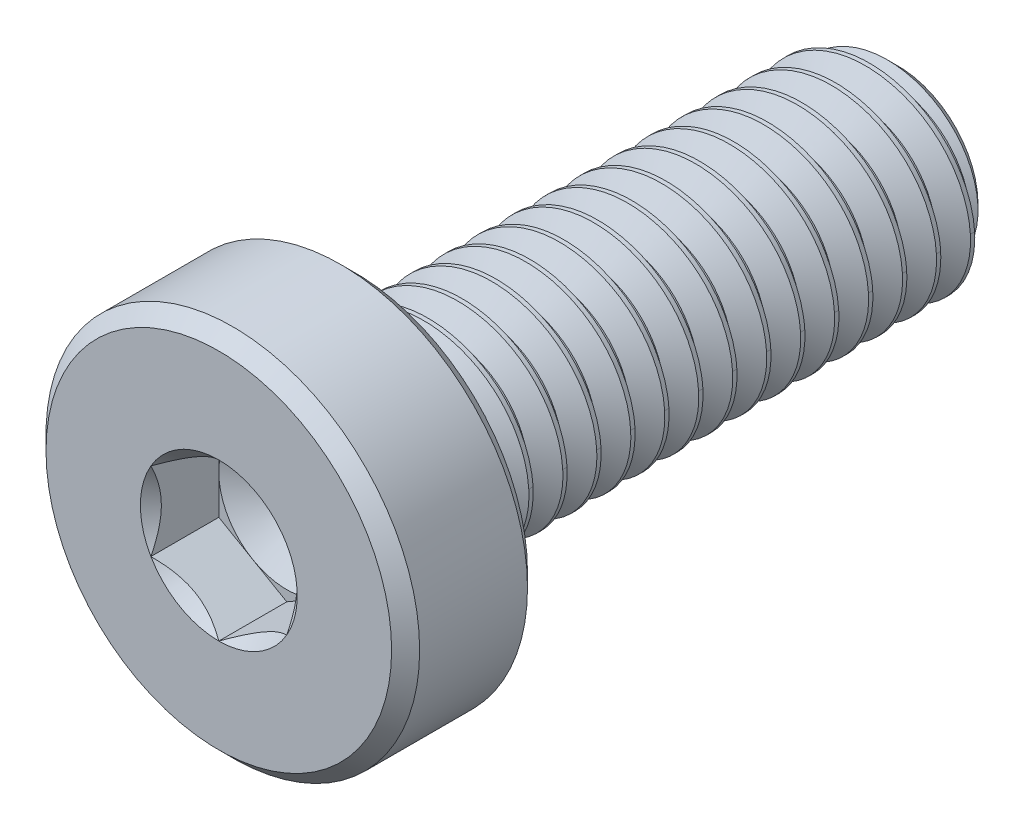
from build123d import *

# Parameters (mm, degrees)
CUT_EXTRUDE1_DEPTH     = 1
CUT_SWEEP1_PITCH       = 0.5
CUT_SWEEP1_HEIGHT      = 8.3125
CUT_SWEEP1_RADIUS      = 1.5
CUT_SWEEP1_START_ANGLE = 90


with BuildPart() as part:
    # Sketch2 → Revolve1 (revolve)
    with BuildSketch(Plane(origin=(0, 0, 0), x_dir=(0, 0, -1), z_dir=(1, 0, 0)), mode=Mode.PRIVATE) as revolve1_sk:
        with BuildLine():
            Line((-3.20625, 2.75), (-3, 2.54375))
            Line((-3, 2.54375), (-3, 1.65))
            ThreePointArc((-3, 1.65), (-2.956066017, 1.543933983), (-2.85, 1.5))
            Line((-2.85, 1.5), (4.675240474, 1.5))
            Line((4.675240474, 1.5), (5, 1.175240474))
            Line((5, 1.175240474), (5, 0))
            Line((5, 0), (-4, 0))
            Line((-4, 0), (-4, 1))
            Line((-4, 1), (-5, 1))
            Line((-5, 1), (-5, 2.54375))
            Line((-5, 2.54375), (-4.79375, 2.75))
            Line((-4.79375, 2.75), (-3.20625, 2.75))
        make_face()
    revolve(revolve1_sk.sketch.rotate(Axis((0, 0, 4), (0, 0, -1)), 90), axis=Axis((0, 0, 4), (0, 0, -1)))

    # Sketch3 → Cut-Extrude1 (cut)
    with BuildSketch(Plane.XY.offset(5)):
        Polygon((0, 1.154700538), (-1, 0.577350269), (-1, -0.577350269), (0, -1.154700538), (1, -0.577350269), (1, 0.577350269), align=None)
    extrude(amount=-CUT_EXTRUDE1_DEPTH, mode=Mode.SUBTRACT)

    # Cut-Extrude2 cone 1 section (through the dimple's axis) → Cut-Extrude2 (revolve, cut)
    with BuildSketch(Plane(origin=(0, 0, 5), x_dir=(0, -1, 0), z_dir=(1, 0, 0))):
        Polygon((0, 0), (1.154700538, 0), (0, 1.154700538), align=None)
    revolve(axis=Axis((0, 0, 5), (0, 0, -1)), mode=Mode.SUBTRACT)

    # Cut-Extrude5 cone 1 section (through the dimple's axis) → Cut-Extrude5 (revolve, cut)
    with BuildSketch(Plane(origin=(0, 0, 4), x_dir=(0, -1, 0), z_dir=(1, 0, 0))):
        Polygon((0, 0), (1, 0), (0, 0.577350269), align=None)
    revolve(axis=Axis((0, 0, 4), (0, 0, -1)), mode=Mode.SUBTRACT)

    # Cut-Sweep1: sweep along a helix
    with BuildLine() as cut_sweep1_path:
        add(Helix(CUT_SWEEP1_PITCH, CUT_SWEEP1_HEIGHT, CUT_SWEEP1_RADIUS, center=(0, 0, -5), direction=(0, 0, 1), mode=Mode.PRIVATE).rotate(Axis((0, 0, -5), (0, 0, 1)), CUT_SWEEP1_START_ANGLE))
    # Sketch8 → Cut-Sweep1 (sweep, cut)
    with BuildSketch(Plane(origin=(0, 0, 0), x_dir=(0, 0, -1), z_dir=(1, 0, 0))):
        Polygon((4.984375, 1.527063294), (5.453125, 1.527063294), (5.25, 1.175240474), (5.1875, 1.175240474), align=None)
    sweep(path=cut_sweep1_path.line, is_frenet=True, mode=Mode.SUBTRACT)

    # Sketch9 → Revolve2 (revolve)
    with BuildSketch(Plane(origin=(0, 0, 0), x_dir=(0, 0, -1), z_dir=(1, 0, 0)), mode=Mode.PRIVATE) as revolve2_sk:
        with BuildLine():
            Line((-3.34375, 0), (-3.34375, 1.65))
            Line((-3.34375, 1.65), (-3, 1.65))
            ThreePointArc((-3, 1.65), (-2.956066017, 1.543933983), (-2.85, 1.5))
            Line((-2.85, 1.5), (-2.5, 1.5))
            Line((-2.5, 1.5), (-1.633974596, 0))
            Line((-1.633974596, 0), (-3.34375, 0))
        make_face()
    revolve(revolve2_sk.sketch.rotate(Axis((0, 0, 1.633974596), (0, 0, 1)), 270), axis=Axis((0, 0, 1.633974596), (0, 0, 1)))


solid = part.part
